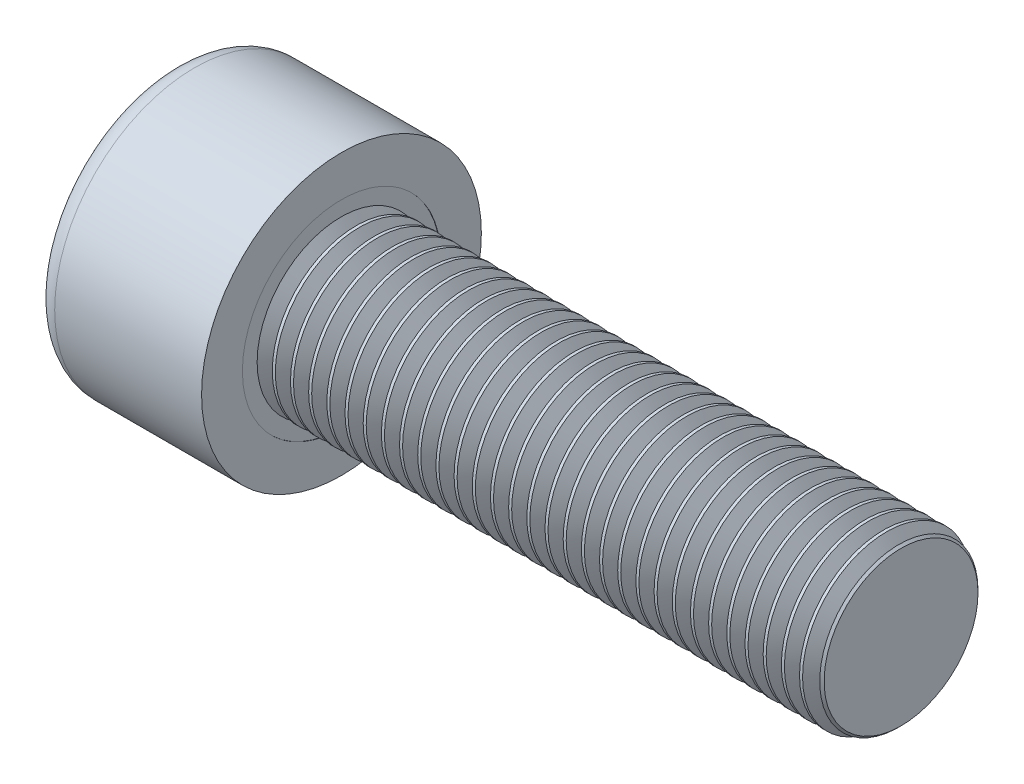
from build123d import *

# Parameters (mm, degrees)
SKETCH1_R           = 5
BASEHEAD_DEPTH      = 6
SKETCH2_R           = 3
BASEBODY_DEPTH      = 20
HEXAGONSOCKET_DEPTH = 3
TOPFILLET_R         = 0.75
CHAMFER1_SIZE       = 0.25
LPATTERN10_COUNT    = 31
LPATTERN10_PITCH    = 0.6498


with BuildPart() as part:
    # Sketch1 → BaseHead (new body)
    with BuildSketch(Plane(origin=(0, 0, 0), x_dir=(0, 0, -1), z_dir=(1, 0, 0))):
        Circle(SKETCH1_R)
    extrude(amount=BASEHEAD_DEPTH)

    # Sketch2 → BaseBody (add)
    with BuildSketch(Plane(origin=(6, 0, 0), x_dir=(0, 0, -1), z_dir=(1, 0, 0))):
        Circle(SKETCH2_R)
    extrude(amount=BASEBODY_DEPTH)

    # Sketch3 → HexagonSocket (cut)
    with BuildSketch(Plane(origin=(0, 0, 0), x_dir=(0, 0, -1), z_dir=(1, 0, 0))):
        Polygon((2.886751346, 0), (1.443375673, 2.5), (-1.443375673, 2.5), (-2.886751346, 0), (-1.443375673, -2.5), (1.443375673, -2.5), align=None)
    extrude(amount=HEXAGONSOCKET_DEPTH, mode=Mode.SUBTRACT)

    # Sketch4 → Cut-Revolve1 (revolve, cut)
    with BuildSketch(Plane(origin=(-4.19613823, 0.75, 0), x_dir=(-1, 0, 0), z_dir=(0, 0, 1))):
        Polygon((-7.19613823, 3.25), (-8.639513903, 0.75), (-7.19613823, 0.75), align=None)
    revolve(axis=Axis((0.838992387, 0, 0), (-1, 0, 0)), mode=Mode.SUBTRACT)

    # TopFillet
    topfillet_edges = [part.edges().sort_by_distance(p)[0] for p in [
        (0, 0, 5),
    ]]
    fillet(topfillet_edges, radius=TOPFILLET_R)

    # Chamfer1
    chamfer1_edges = [part.edges().sort_by_distance(p)[0] for p in [
        (26, 0, 3),
    ]]
    chamfer(chamfer1_edges, length=CHAMFER1_SIZE)

    # Sketch5 → Cut-Revolve10 (revolve, cut)
    with BuildSketch(Plane.XY):
        Polygon((25.75, 2.531047244), (26.02075, 3), (26.02075, 3.5415), (25.47925, 3.5415), (25.47925, 3), align=None)
    cut_revolve10 = revolve(axis=Axis((0, 0, 0), (1, 0, 0)), mode=Mode.SUBTRACT)

    # LPattern10: Cut-Revolve10 ×31
    with Locations(*[(-i * LPATTERN10_PITCH, 0, 0) for i in range(1, LPATTERN10_COUNT)]):
        add(cut_revolve10, mode=Mode.SUBTRACT)


solid = part.part
